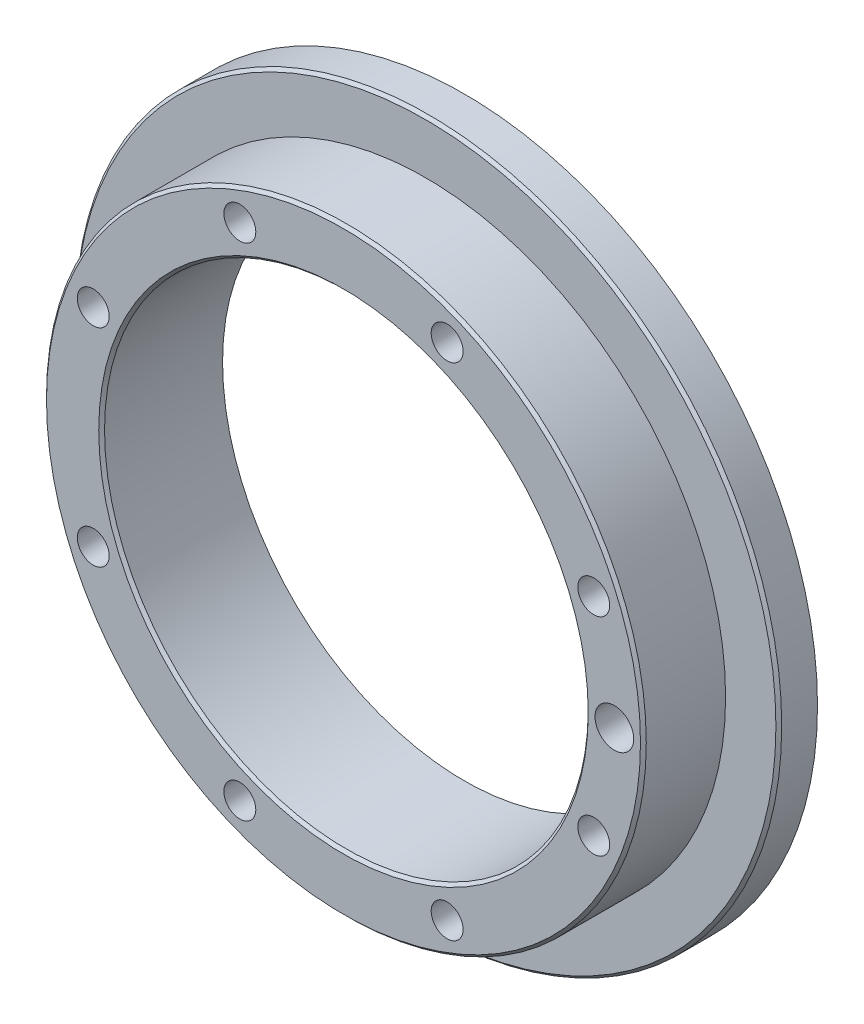
from build123d import *

# Parameters (mm, degrees)
CHAMFER1_SIZE             = 0.3
F_4_000_X_6_0_DOWEL_D     = 4
F_4_000_X_6_0_DOWEL_DEPTH = 6
F_4_000_X_6_0_DOWEL_TIP   = 1.201721238
CIRPATTERN1_COUNT         = 8


with BuildPart() as part:
    # Sketch1 → Revolve1 (revolve)
    with BuildSketch(Plane(origin=(0, 0, 0), x_dir=(1, 0, 0), z_dir=(0, 1, 0))):
        Polygon((25, 0), (31, 0), (31, 8.5), (36.5, 8.5), (36.5, 12.5), (25, 12.5), align=None)
    revolve(axis=Axis((0, 0, 0), (0, 0, -1)))

    # Chamfer1
    chamfer1_edges = [part.edges().sort_by_distance(p)[0] for p in [
        (-36.5, 0, -8.5),
        (-25, 0, 0),
        (-31, 0, 0),
    ]]
    chamfer(chamfer1_edges, length=CHAMFER1_SIZE)

    # Ø4.000 x 6.0 Dowel
    with Locations(Plane.XY):
        with Locations((28, 0)):
            Hole(F_4_000_X_6_0_DOWEL_D / 2, depth=F_4_000_X_6_0_DOWEL_DEPTH)
            with Locations((0, 0, -(F_4_000_X_6_0_DOWEL_DEPTH + F_4_000_X_6_0_DOWEL_TIP / 2))):  # 118° drill point
                Cone(0, F_4_000_X_6_0_DOWEL_D / 2, F_4_000_X_6_0_DOWEL_TIP, mode=Mode.SUBTRACT)

    # Sketch5 → M4x0.7 x 6.0 Tapped Hole (revolve, cut)
    with BuildSketch(Plane(origin=(25.86862691, -10.715136106, 0), x_dir=(0, -1, 0), z_dir=(1, 0, 0))):
        Polygon((0, 0), (0, 12.491420021), (1.65, 11.5), (1.65, 0), align=None)
    m4x0_7_x_6_0_tapped_hole = revolve(axis=Axis((25.86862691, -10.715136106, 6.35), (0, 0, -1)), mode=Mode.SUBTRACT)

    # CirPattern1: M4x0.7 x 6.0 Tapped Hole ×8 about axis
    cirpattern1_axis = Axis((0, 0, 0), (0, 0, 1))
    for i in range(1, CIRPATTERN1_COUNT):
        add(m4x0_7_x_6_0_tapped_hole.rotate(cirpattern1_axis, i * 360 / CIRPATTERN1_COUNT), mode=Mode.SUBTRACT)


solid = part.part
